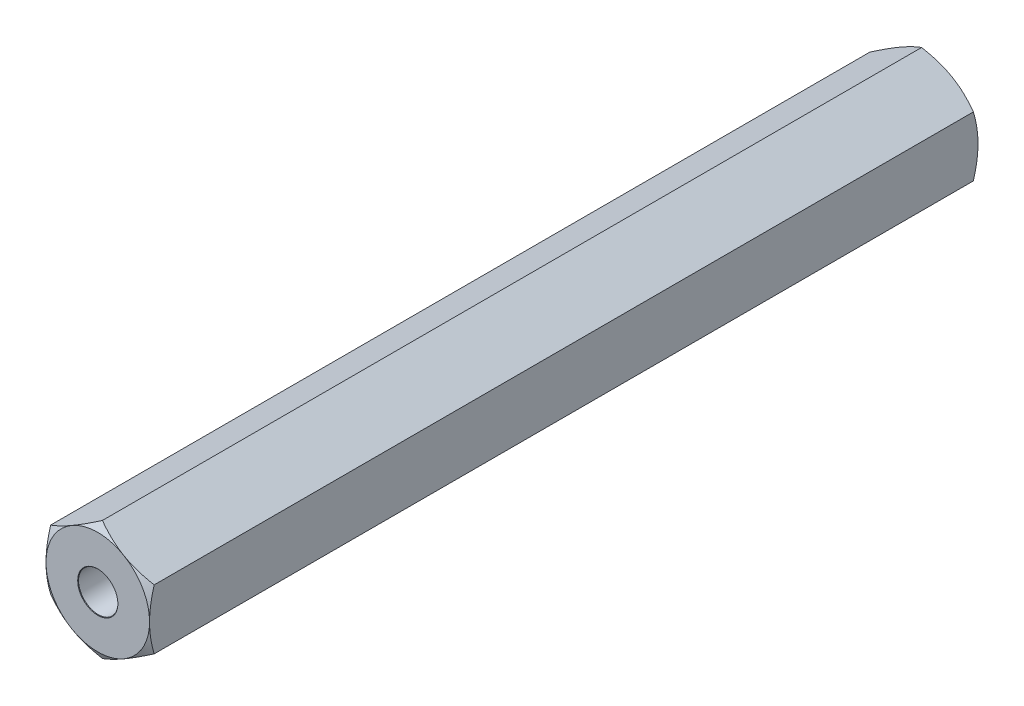
from build123d import *

# Parameters (mm, degrees)
EXTRUDE1_DEPTH          = 50.8
EXTRUDE1_DEPTH_BACK     = 50.8
SKETCH1_R               = 2.413
SKETCH8_OUTSIDE_W       = 392.404
SKETCH8_OUTSIDE_H       = 394.368
SKETCH8_OUTSIDE_R       = 6.35
EXTRUDE4_DEPTH          = 103.061970554
EXTRUDE4_DRAFT          = -60
MIRROR1_COPY_1_SKETCH_W = 392.404
MIRROR1_COPY_1_SKETCH_H = 394.368
MIRROR1_COPY_1_SKETCH_R = 6.35
MIRROR1_COPY_1_DEPTH    = 103.061970554
MIRROR1_COPY_1_DRAFT    = -60


with BuildPart() as part:
    # Sketch1 → Extrude1 (new, two sides: drawn at the far end of the back side and taken through both)
    with BuildSketch(Plane.XY.offset(-EXTRUDE1_DEPTH_BACK)):
        Polygon((0, 7.332348419), (-6.35, 3.666174209), (-6.35, -3.666174209), (0, -7.332348419), (6.35, -3.666174209), (6.35, 3.666174209), align=None)
        Circle(SKETCH1_R, mode=Mode.SUBTRACT)
    extrude(amount=EXTRUDE1_DEPTH + EXTRUDE1_DEPTH_BACK)

    # Extrude3 cone 1 section (through the dimple's axis) → Extrude3 (revolve, cut)
    with BuildSketch(Plane(origin=(0, 0, -50.8), x_dir=(0, 1, 0), z_dir=(1, 0, 0))):
        Polygon((0, 0), (2.4638, 0), (0, 2.642102028), align=None)
    extrude3 = revolve(axis=Axis((0, 0, -50.8), (0, 0, 1)), mode=Mode.SUBTRACT)


with BuildPart() as extrude4_tool:
    # Sketch8 outside → Extrude4 (with draft: the straight prism first)
    with BuildSketch(Plane(origin=(0, 0, -50.8), x_dir=(-1, 0, 0), z_dir=(0, 0, -1))):
        Rectangle(SKETCH8_OUTSIDE_W, SKETCH8_OUTSIDE_H)
        Circle(SKETCH8_OUTSIDE_R, mode=Mode.SUBTRACT)
    extrude(amount=-EXTRUDE4_DEPTH)
    # Extrude4: the draft: its side faces are tilted about the plane it starts from
    extrude4_sides = [extrude4_tool.faces().sort_by_distance(p)[0] for p in [
        (0, -197.184, 0.730985277),
        (-196.202, 0, 0.730985277),
        (0, 197.184, 0.730985277),
        (196.202, 0, 0.730985277),
        (6.35, 0, 0.730985277),
    ]]
    draft(extrude4_sides, Plane(origin=(0, 0, -50.8), x_dir=(-1, 0, 0), z_dir=(0, 0, -1)), EXTRUDE4_DRAFT)


with BuildPart() as part_1:
    add(part.part)

    # Extrude4: cut by extrude4_tool
    add(extrude4_tool.part, mode=Mode.SUBTRACT)

    # Mirror1: Extrude3 across plane
    add(extrude3.mirror(Plane.XY), mode=Mode.SUBTRACT)


with BuildPart() as mirror1_copy_1_tool:
    # Mirror1 copy 1 sketch → Mirror1 copy 1 (with draft: the straight prism first)
    with BuildSketch(Plane(origin=(0, 0, 50.8), x_dir=(-1, 0, 0), z_dir=(0, 0, 1))):
        Rectangle(MIRROR1_COPY_1_SKETCH_W, MIRROR1_COPY_1_SKETCH_H)
        Circle(MIRROR1_COPY_1_SKETCH_R, mode=Mode.SUBTRACT)
    extrude(amount=-MIRROR1_COPY_1_DEPTH)
    # Mirror1 copy 1: the draft: its side faces are tilted about the plane it starts from
    mirror1_copy_1_sides = [mirror1_copy_1_tool.faces().sort_by_distance(p)[0] for p in [
        (0, -197.184, -0.730985277),
        (-196.202, 0, -0.730985277),
        (0, 197.184, -0.730985277),
        (196.202, 0, -0.730985277),
        (6.35, 0, -0.730985277),
    ]]
    draft(mirror1_copy_1_sides, Plane(origin=(0, 0, 50.8), x_dir=(-1, 0, 0), z_dir=(0, 0, 1)), MIRROR1_COPY_1_DRAFT)


with BuildPart() as part_2:
    add(part_1.part)

    # Mirror1 copy 1: cut by mirror1_copy_1_tool
    add(mirror1_copy_1_tool.part, mode=Mode.SUBTRACT)


solid = part_2.part
